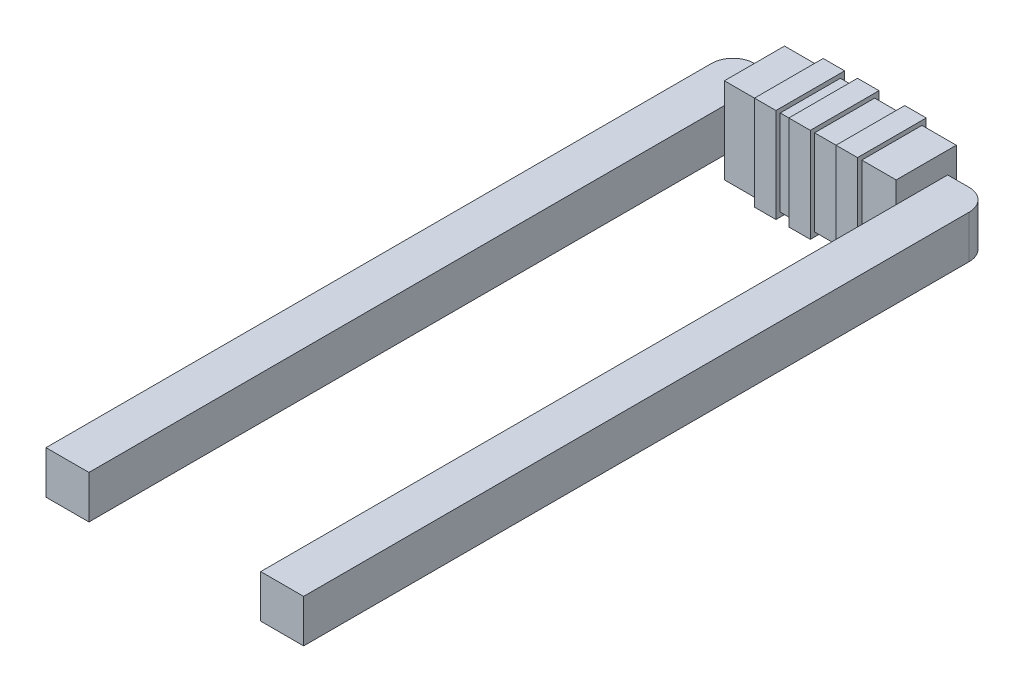
from build123d import *

# Parameters (mm, degrees)
BOSS_EXTRUDE1_DEPTH = 1
SKETCH3_W           = 4
SKETCH3_H           = 1.4
BOSS_EXTRUDE2_DEPTH = 1.5
SKETCH4_W           = 4
SKETCH4_H           = 1.4
CUT_EXTRUDE1_DEPTH  = 1
SKETCH5_W           = 0.5
SKETCH5_H           = 1.6
BOSS_EXTRUDE4_DEPTH = 2.1
SKETCH6_W           = 0.5
SKETCH6_H           = 1.6
BOSS_EXTRUDE5_DEPTH = 0.1


with BuildPart() as part:
    # Sketch1 → Boss-Extrude1 (new body)
    with BuildSketch(Plane(origin=(0, 0, 0), x_dir=(1, 0, 0), z_dir=(0, 1, 0))):
        with BuildLine():
            Line((-1.459627329, 0), (-1.459627329, 15.5))
            ThreePointArc((-1.459627329, 15.5), (-1.31318072, 15.853553391), (-0.959627329, 16))
            Line((-0.959627329, 16), (4.040372671, 16))
            ThreePointArc((4.040372671, 16), (4.393926061, 15.853553391), (4.540372671, 15.5))
            Line((4.540372671, 15.5), (4.540372671, 0))
            Line((4.540372671, 0), (3.540372671, 0))
            Line((3.540372671, 0), (3.540372671, 15))
            Line((3.540372671, 15), (-0.459627329, 15))
            Line((-0.459627329, 15), (-0.459627329, 0))
            Line((-0.459627329, 0), (-1.459627329, 0))
        make_face()
    extrude(amount=BOSS_EXTRUDE1_DEPTH)

    # Sketch3 → Boss-Extrude2 (add, symmetric)
    with BuildSketch(Plane(origin=(0, 1, 0), x_dir=(1, 0, 0), z_dir=(0, 1, 0))):
        with Locations((1.540372671, 15.5)):
            Rectangle(SKETCH3_W, SKETCH3_H)
    extrude(amount=BOSS_EXTRUDE2_DEPTH, both=True)

    # Sketch4 → Cut-Extrude1 (cut)
    with BuildSketch(Plane(origin=(0, 2.5, 0), x_dir=(1, 0, 0), z_dir=(0, 1, 0))):
        with Locations((1.540372671, 15.5)):
            Rectangle(SKETCH4_W, SKETCH4_H)
    extrude(amount=-CUT_EXTRUDE1_DEPTH, mode=Mode.SUBTRACT)

    # Sketch5 → Boss-Extrude4 (add)
    with BuildSketch(Plane(origin=(0, 1.5, 0), x_dir=(1, 0, 0), z_dir=(0, 1, 0))):
        with Locations((0.590372671, 15.5)):
            Rectangle(SKETCH5_W, SKETCH5_H)
        with Locations((1.390372671, 15.5)):
            Rectangle(SKETCH5_W, SKETCH5_H)
        with Locations((2.490372671, 15.5)):
            Rectangle(SKETCH5_W, SKETCH5_H)
    extrude(amount=-BOSS_EXTRUDE4_DEPTH)

    # Sketch6 → Boss-Extrude5 (add)
    with BuildSketch(Plane(origin=(0, 1.5, 0), x_dir=(1, 0, 0), z_dir=(0, 1, 0))):
        with Locations((0.590372671, 15.5)):
            Rectangle(SKETCH6_W, SKETCH6_H)
        with Locations((1.390372671, 15.5)):
            Rectangle(SKETCH6_W, SKETCH6_H)
        with Locations((2.490372671, 15.5)):
            Rectangle(SKETCH6_W, SKETCH6_H)
    extrude(amount=BOSS_EXTRUDE5_DEPTH)


solid = part.part
